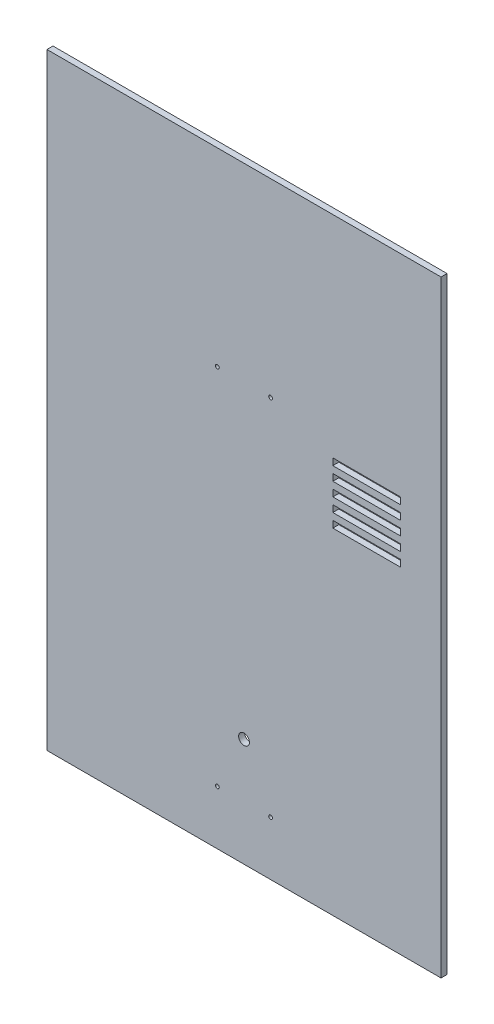
from build123d import *

# Parameters (mm, degrees)
SKETCH1_W           = 370
SKETCH1_H           = 5.6388
BOSS_EXTRUDE1_DEPTH = 570
SKETCH2_R           = 5.08
CUT_EXTRUDE1_DEPTH  = 6.6388
SKETCH3_R           = 1.778
CUT_EXTRUDE2_DEPTH  = 6.6388
SKETCH4_W           = 63.5
SKETCH4_H           = 6.35
CUT_EXTRUDE3_DEPTH  = 6.6388
LPATTERN1_COUNT     = 5
LPATTERN1_PITCH     = 12.7


with BuildPart() as part:
    # Sketch1 → Boss-Extrude1 (new body)
    with BuildSketch(Plane(origin=(0, 0, 0), x_dir=(1, 0, 0), z_dir=(0, 1, 0))):
        Rectangle(SKETCH1_W, SKETCH1_H)
    extrude(amount=BOSS_EXTRUDE1_DEPTH)

    # Sketch2 → Cut-Extrude1 (cut, through all)
    with BuildSketch(Plane.XY.offset(2.8194)):
        with Locations((0, 101.6)):
            Circle(SKETCH2_R)
    extrude(amount=-CUT_EXTRUDE1_DEPTH, mode=Mode.SUBTRACT)

    # Sketch3 → Cut-Extrude2 (cut, through all)
    with BuildSketch(Plane.XY.offset(2.8194)):
        with Locations((-25, 50.8)):
            Circle(SKETCH3_R)
        with Locations((25, 50.8)):
            Circle(SKETCH3_R)
        with Locations((-25, 392)):
            Circle(SKETCH3_R)
        with Locations((25, 392)):
            Circle(SKETCH3_R)
    extrude(amount=-CUT_EXTRUDE2_DEPTH, mode=Mode.SUBTRACT)

    # Sketch4 → Cut-Extrude3 (cut, through all)
    with BuildSketch(Plane.XY.offset(2.8194)):
        with Locations((115.15, 318.175)):
            Rectangle(SKETCH4_W, SKETCH4_H)
    cut_extrude3 = extrude(amount=-CUT_EXTRUDE3_DEPTH, mode=Mode.SUBTRACT)

    # LPattern1: Cut-Extrude3 ×5
    with Locations(*[(0, i * LPATTERN1_PITCH, 0) for i in range(1, LPATTERN1_COUNT)]):
        add(cut_extrude3, mode=Mode.SUBTRACT)


solid = part.part
